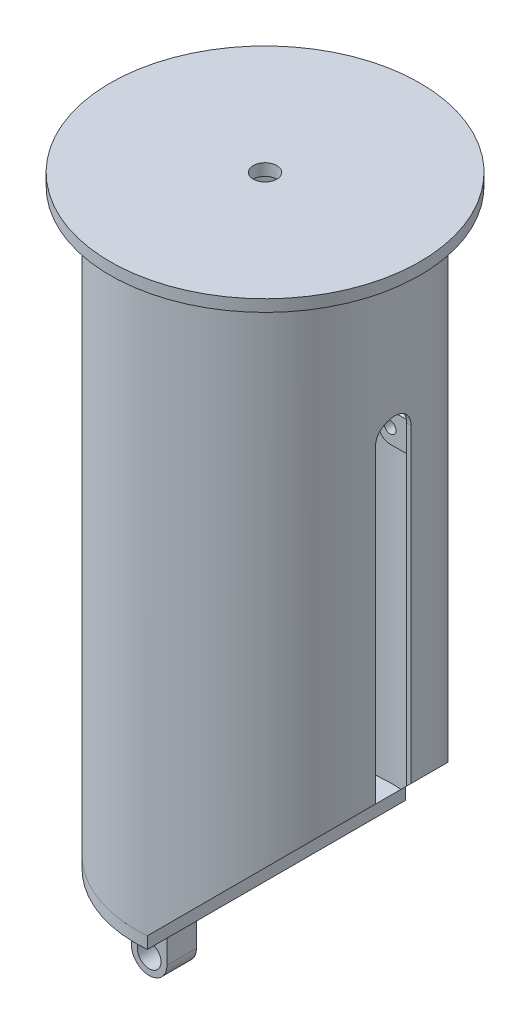
from build123d import *

# Parameters (mm, degrees)
CORTE_EXTRUS_O1_DEPTH      = 132
CORTE_EXTRUS_O1_DEPTH_BACK = 132
RESSALTO_EXTRUS_O1_DEPTH   = 10
ESBO_O4_R                  = 10
RESSALTO_EXTRUS_O2_DEPTH   = 12.5
RESSALTO_EXTRUS_O3_START   = 20
ESBO_O5_R                  = 5
RESSALTO_EXTRUS_O3_DEPTH   = 8
CORTE_EXTRUS_O2_DEPTH      = 132


with BuildPart() as part:
    # Esboço1 → Revolução1 (revolve)
    with BuildSketch(Plane.XY):
        Polygon((10, 500), (131, 500), (131, 490), (109.54, 490), (109.54, 0), (105.78, 0), (105.78, 490), (10, 490), align=None)
    revolve(axis=Axis((0, 0, 0), (0, 1, 0)))

    # Esboço2 → Corte-extrusão1 (cut, two sides)
    with BuildSketch(Plane.XY) as corte_extrus_o1_sk:
        Polygon((9.54, 0), (109.54, 100), (109.54, 0), align=None)
    extrude(amount=CORTE_EXTRUS_O1_DEPTH, mode=Mode.SUBTRACT)
    extrude(corte_extrus_o1_sk.sketch, amount=-CORTE_EXTRUS_O1_DEPTH_BACK, mode=Mode.SUBTRACT)

    # Esboço5 → Ressalto-extrusão3 (add)
    with BuildSketch(Plane.XY.offset(RESSALTO_EXTRUS_O3_START)):
        with BuildLine():
            Line((105.78, 358.74), (85.78, 358.74))
            ThreePointArc((85.78, 358.74), (78.708932188, 355.811067812), (75.78, 348.74))
            Line((75.78, 348.74), (75.78, 343.74))
            ThreePointArc((75.78, 343.74), (78.708932188, 336.668932188), (85.78, 333.74))
            Line((85.78, 333.74), (105.78, 333.74))
            Line((105.78, 333.74), (105.78, 358.74))
        make_face()
        with Locations((85.78, 346.24)):
            Circle(ESBO_O5_R, mode=Mode.SUBTRACT)
    ressalto_extrus_o3 = extrude(amount=RESSALTO_EXTRUS_O3_DEPTH)

    # Espelhar1: Ressalto-extrusão3 across plane
    add(ressalto_extrus_o3.mirror(Plane.XY))

    # Esboço6 → Corte-extrusão2 (cut, through all)
    with BuildSketch(Plane(origin=(0, 0, 0), x_dir=(0, 0, -1), z_dir=(1, 0, 0))):
        with BuildLine():
            Line((15, 361.24), (15, 15))
            ThreePointArc((15, 15), (0, 0), (-15, 15))
            Line((-15, 15), (-15, 361.24))
            ThreePointArc((-15, 361.24), (0, 376.24), (15, 361.24))
        make_face()
    extrude(amount=CORTE_EXTRUS_O2_DEPTH, mode=Mode.SUBTRACT)


with BuildPart() as body_2:
    # Esboço3 → Ressalto-extrusão1 (new body)
    with BuildSketch(Plane.XZ):
        with BuildLine():
            Line((9.54, 109.123782926), (9.54, -109.123782926))
            ThreePointArc((9.54, -109.123782926), (-109.54, 0), (9.54, 109.123782926))
        make_face()
    extrude(amount=RESSALTO_EXTRUS_O1_DEPTH)

    # Esboço4 → Ressalto-extrusão2 (add, symmetric)
    with BuildSketch(Plane.XY):
        with BuildLine():
            Line((-100.54, -10), (-100.54, -110))
            ThreePointArc((-100.54, -110), (-85.54, -125), (-70.54, -110))
            Line((-70.54, -110), (-70.54, -10))
            Line((-70.54, -10), (-100.54, -10))
        make_face()
        with Locations((-85.54, -110)):
            Circle(ESBO_O4_R, mode=Mode.SUBTRACT)
    extrude(amount=RESSALTO_EXTRUS_O2_DEPTH, both=True)


solid = Compound([part.part, body_2.part])
